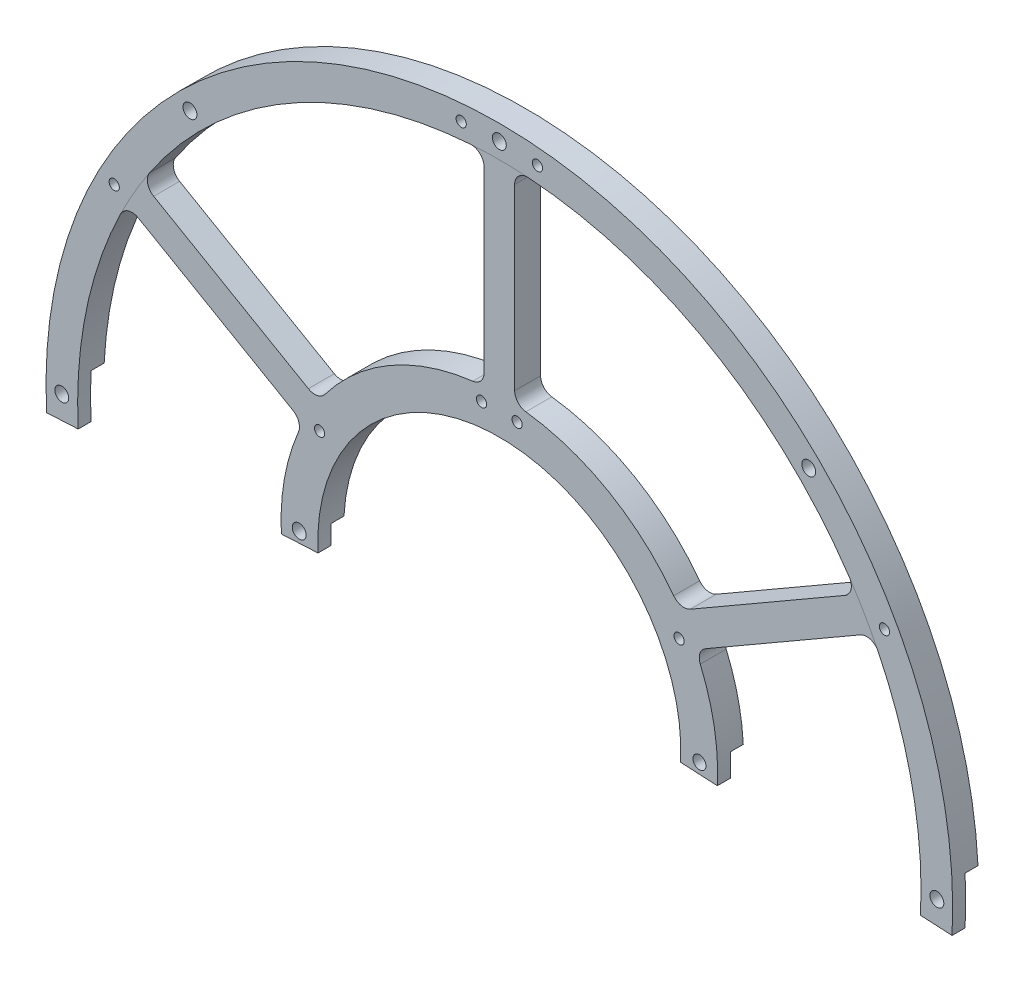
from build123d import *

# Parameters (mm, degrees)
SKETCH1_R                = 111
SKETCH1_R_2              = 103.25
BOSS_EXTRUDE1_DEPTH      = 3.175
SKETCH1_R_3              = 53.45
SKETCH1_R_4              = 44.45
BOSS_EXTRUDE1_2_DEPTH    = 3.175
BOSS_EXTRUDE2_DEPTH      = 6.35
FILLET1_R                = 3.125
CIRPATTERN2_COUNT        = 6
FILLET1_OF_CIRPATTERN2_R = 3.125
M3_CLEARANCE_HOLE1_D     = 3.4
CIRPATTERN3_COUNT        = 8
SKETCH5_R                = 1.7
CUT_EXTRUDE1_DEPTH       = 1
CUT_EXTRUDE1_DEPTH_BACK  = 7.35
CUT_EXTRUDE6_DEPTH       = 4
M3_CLEARANCE_HOLE2_D     = 3.4
M3_CLEARANCE_HOLE3_D     = 3.2
M3X0_5_TAPPED_HOLE1_D    = 2.5


with BuildPart() as part:
    # Sketch1 → Boss-Extrude1 (new body, symmetric)
    with BuildSketch(Plane.XY):
        Circle(SKETCH1_R)
        Circle(SKETCH1_R_2, mode=Mode.SUBTRACT)
    extrude(amount=BOSS_EXTRUDE1_DEPTH, both=True)



with BuildPart() as body_2:
    # Sketch1 → Boss-Extrude1 2 (new body, symmetric)
    with BuildSketch(Plane.XY):
        Circle(SKETCH1_R_3)
        Circle(SKETCH1_R_4, mode=Mode.SUBTRACT)
    extrude(amount=BOSS_EXTRUDE1_2_DEPTH, both=True)


with BuildPart() as part_1:
    add(part.part)

    add(body_2.part)  # Boss-Extrude2 merges body 2
    # Sketch2 → Boss-Extrude2 (add, through all)
    with BuildSketch(Plane.XY.offset(3.175)):
        with BuildLine():
            Line((3.75, -103.181878254), (3.75, -53.318289545))
            ThreePointArc((3.75, -53.318289545), (0, -53.45), (-3.75, -53.318289545))
            Line((-3.75, -53.318289545), (-3.75, -103.181878254))
            ThreePointArc((-3.75, -103.181878254), (0, -103.25), (3.75, -103.181878254))
        make_face()
    boss_extrude2 = extrude(amount=-BOSS_EXTRUDE2_DEPTH)

    # Fillet1
    fillet1_edges = [part_1.edges().sort_by_distance(p)[0] for p in [
        (-3.75, -53.318289545, 0),
        (3.75, -53.318289545, 0),
        (3.75, -103.181878254, 0),
        (-3.75, -103.181878254, 0),
    ]]
    fillet(fillet1_edges, radius=FILLET1_R)

    # CirPattern2: Boss-Extrude2 ×6 about axis
    cirpattern2_axis = Axis((0, 0, 0), (0, 0, 1))
    for i in range(1, CIRPATTERN2_COUNT):
        add(boss_extrude2.rotate(cirpattern2_axis, i * 360 / CIRPATTERN2_COUNT))

    # Fillet1 of CirPattern2
    fillet1_of_cirpattern2_edges = [part_1.edges().sort_by_distance(p)[0] for p in [
        (44.299993232, -29.906740037, 0),
        (48.049993232, -23.411549508, 0),
        (91.233127778, -48.343343863, 0),
        (87.483127778, -54.838534391, 0),
        (48.049993232, 23.411549508, 0),
        (44.299993232, 29.906740037, 0),
        (87.483127778, 54.838534391, 0),
        (91.233127778, 48.343343863, 0),
        (3.75, 53.318289545, 0),
        (-3.75, 53.318289545, 0),
        (-3.75, 103.181878254, 0),
        (3.75, 103.181878254, 0),
        (-44.299993232, 29.906740037, 0),
        (-48.049993232, 23.411549508, 0),
        (-91.233127778, 48.343343863, 0),
        (-87.483127778, 54.838534391, 0),
        (-48.049993232, -23.411549508, 0),
        (-44.299993232, -29.906740037, 0),
        (-87.483127778, -54.838534391, 0),
        (-91.233127778, -48.343343863, 0),
    ]]
    fillet(fillet1_of_cirpattern2_edges, radius=FILLET1_OF_CIRPATTERN2_R)

    # M3 Clearance Hole1 (through all)
    with Locations(Plane.XY.offset(3.175)):
        with Locations((0, 107.125)):
            m3_clearance_hole1 = Hole(M3_CLEARANCE_HOLE1_D / 2)

    # CirPattern3: M3 Clearance Hole1 ×8 about axis
    cirpattern3_axis = Axis((0, 0, 0), (0, 0, 1))
    for i in range(1, CIRPATTERN3_COUNT):
        add(m3_clearance_hole1.rotate(cirpattern3_axis, i * 360 / CIRPATTERN3_COUNT), mode=Mode.SUBTRACT)

    # Sketch5 → Cut-Extrude1 (cut, two sides)
    with BuildSketch(Plane(origin=(0, 0, -3.175), x_dir=(-1, 0, 0), z_dir=(0, 0, -1))) as cut_extrude1_sk:
        with BuildLine():
            Line((53.376748633, -2.797356861), (44.38908282, -2.326333255))
            ThreePointArc((44.38908282, -2.326333255), (0, -44.45), (-44.38908282, -2.326333255))
            Line((-44.38908282, -2.326333255), (-53.376748633, -2.797356861))
            ThreePointArc((-53.376748633, -2.797356861), (-52.077963884, -12.032795921), (-49.193633081, -20.901889013))
            ThreePointArc((-49.193633081, -20.901889013), (-49.106095125, -23.114991521), (-50.507280946, -24.830265231))
            Line((-50.507280946, -24.830265231), (-88.3811414, -46.69674876))
            ThreePointArc((-88.3811414, -46.69674876), (-90.855666768, -46.979371485), (-92.750871157, -45.363403748))
            ThreePointArc((-92.750871157, -45.363403748), (-99.947075975, -25.906456802), (-103.108499463, -5.403687482))
            Line((-103.108499463, -5.403687482), (-110.847878358, -5.809291143))
            ThreePointArc((-110.847878358, -5.809291143), (0, -111), (110.847878358, -5.809291143))
            Line((110.847878358, -5.809291143), (103.108499463, -5.403687482))
            ThreePointArc((103.108499463, -5.403687482), (99.947075975, -25.906456802), (92.750871157, -45.363403748))
            ThreePointArc((92.750871157, -45.363403748), (90.855666768, -46.979371485), (88.3811414, -46.69674876))
            Line((88.3811414, -46.69674876), (50.507280946, -24.830265231))
            ThreePointArc((50.507280946, -24.830265231), (49.106095125, -23.114991521), (49.193633081, -20.901889013))
            ThreePointArc((49.193633081, -20.901889013), (52.077963884, -12.032795921), (53.376748633, -2.797356861))
        make_face()
        with Locations((-75.748813935, -75.748813935)):
            Circle(SKETCH5_R, mode=Mode.SUBTRACT)
        with Locations((0, -107.125)):
            Circle(SKETCH5_R, mode=Mode.SUBTRACT)
        with BuildLine():
            ThreePointArc((-46.757280946, -31.32545576), (-44.571217428, -30.969630098), (-42.698383412, -32.151991446))
            ThreePointArc((-42.698383412, -32.151991446), (-26.725, -46.289057832), (-6.495249669, -53.053880459))
            ThreePointArc((-6.495249669, -53.053880459), (-4.534877697, -54.084621619), (-3.75, -56.155720991))
            Line((-3.75, -56.155720991), (-3.75, -99.888688048))
            ThreePointArc((-3.75, -99.888688048), (-4.742504224, -102.173001242), (-7.089575531, -103.006312519))
            ThreePointArc((-7.089575531, -103.006312519), (-51.625, -89.417122941), (-85.661295626, -57.642908771))
            ThreePointArc((-85.661295626, -57.642908771), (-86.113162544, -55.193629757), (-84.6311414, -53.191939288))
            Line((-84.6311414, -53.191939288), (-46.757280946, -31.32545576))
        make_face(mode=Mode.SUBTRACT)
        with BuildLine():
            ThreePointArc((84.6311414, -53.191939288), (86.113162544, -55.193629757), (85.661295626, -57.642908771))
            ThreePointArc((85.661295626, -57.642908771), (51.625, -89.417122941), (7.089575531, -103.006312519))
            ThreePointArc((7.089575531, -103.006312519), (4.742504224, -102.173001242), (3.75, -99.888688048))
            Line((3.75, -99.888688048), (3.75, -56.155720991))
            ThreePointArc((3.75, -56.155720991), (4.534877697, -54.084621619), (6.495249669, -53.053880459))
            ThreePointArc((6.495249669, -53.053880459), (26.725, -46.289057832), (42.698383412, -32.151991446))
            ThreePointArc((42.698383412, -32.151991446), (44.571217428, -30.969630098), (46.757280946, -31.32545576))
            Line((46.757280946, -31.32545576), (84.6311414, -53.191939288))
        make_face(mode=Mode.SUBTRACT)
        with Locations((75.748813935, -75.748813935)):
            Circle(SKETCH5_R, mode=Mode.SUBTRACT)
    extrude(amount=CUT_EXTRUDE1_DEPTH, mode=Mode.SUBTRACT)
    extrude(cut_extrude1_sk.sketch, amount=-CUT_EXTRUDE1_DEPTH_BACK, mode=Mode.SUBTRACT)

    # Sketch6 → Cut-Extrude6 (cut)
    with BuildSketch(Plane.XY):
        Polygon((0, 0), (199.725906951, 10.467191249), (199.725906951, -44.207372647), align=None)
    cut_extrude6 = extrude(amount=-CUT_EXTRUDE6_DEPTH, mode=Mode.SUBTRACT)

    # Mirror1: Cut-Extrude6 across plane
    add(cut_extrude6.mirror(Plane(origin=(0, 0, 0), x_dir=(0, 0, 1), z_dir=(1, 0, 0))), mode=Mode.SUBTRACT)

    # M3 Clearance Hole2 (through all)
    with Locations(Plane.XY.offset(3.175)):
        with Locations((-49, 0)):
            Hole(M3_CLEARANCE_HOLE2_D / 2)

    # M3 Clearance Hole3 (through all)
    with Locations(Plane.XY.offset(3.175)):
        with Locations((49, 0)):
            Hole(M3_CLEARANCE_HOLE3_D / 2)

    # M3x0.5 Tapped Hole1 (through all)
    with Locations(Plane(origin=(0, 0, -3.175), x_dir=(-1, 0, 0), z_dir=(0, 0, -1))):
        with Locations((-9.336558942, 106.717357033), (-94.29157403, 50.841564609), (-44.010069559, 23.730018487), (-4.357787137, 49.809734905), (4.357787137, 49.809734905), (44.010069559, 23.730018487), (94.29157403, 50.841564609), (9.336558942, 106.717357033)):
            Hole(M3X0_5_TAPPED_HOLE1_D / 2)


solid = part_1.part
